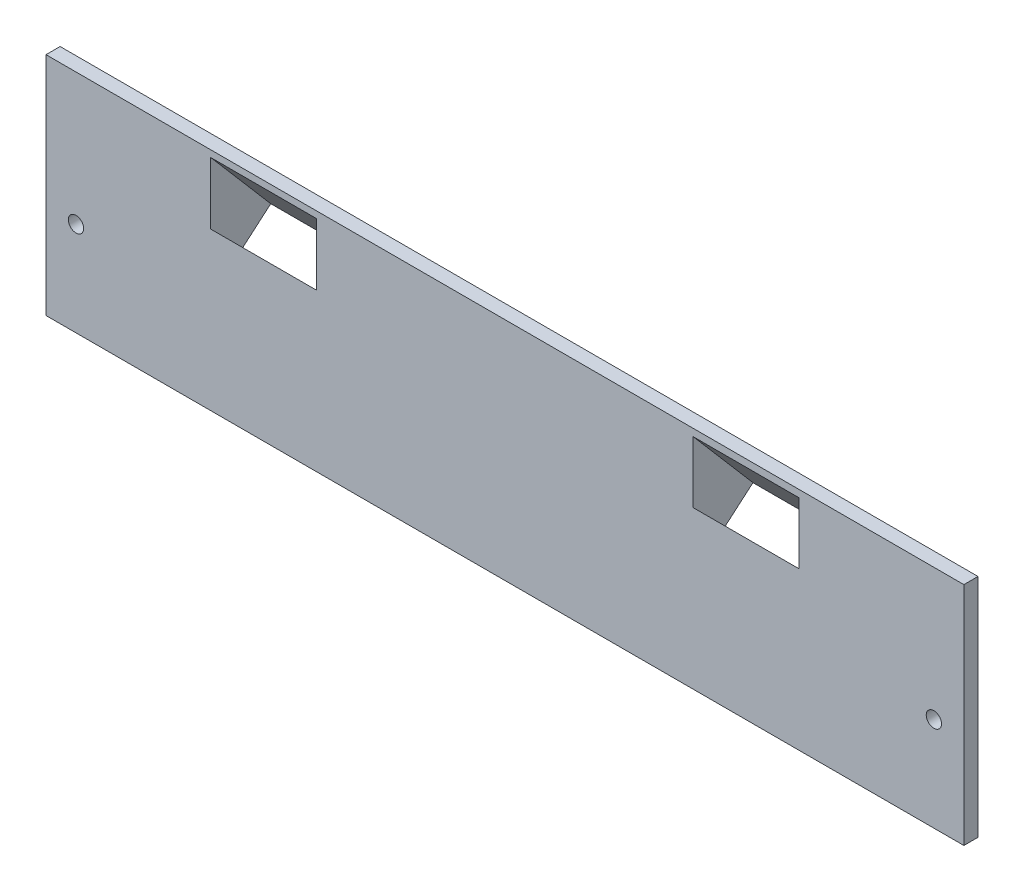
from build123d import *

# Parameters (mm, degrees)
CROQUIS1_W                 = 195
CROQUIS1_H                 = 38
CROQUIS1_R                 = 1.625
SALIENTE_EXTRUIR1_DEPTH    = 3
CROQUIS8_W                 = 195
CROQUIS8_H                 = 3
SALIENTE_EXTRUIR5_DEPTH    = 5
CROQUIS9_W                 = 195
CROQUIS9_H                 = 3
SALIENTE_EXTRUIR6_DEPTH    = 5
SALIENTE_EXTRUIR7_START    = -25
SALIENTE_EXTRUIR7_DEPTH    = 35
CROQUIS11_W                = 22.5
CROQUIS11_H                = 8.5
CORTAR_EXTRUIR4_DEPTH      = 24.953943013
CORTAR_EXTRUIR4_DEPTH_BACK = 22.667360251
CORTAR_EXTRUIR5_REACH      = 172
CROQUIS13_R                = 1
CORTAR_EXTRUIR6_DEPTH      = 5
SALIENTE_EXTRUIR8_START    = -25
SALIENTE_EXTRUIR8_DEPTH    = 35
CROQUIS16_W                = 22.5
CROQUIS16_H                = 8.572274099
CORTAR_EXTRUIR7_DEPTH      = 27.836407603
CORTAR_EXTRUIR7_DEPTH_BACK = 17.667360251
CROQUIS17_R                = 1
CORTAR_EXTRUIR8_DEPTH      = 5
CROQUIS18_W                = 35
CROQUIS18_H                = 12
CROQUIS18_R                = 1
CROQUIS18_W_2              = 22.5
CROQUIS18_H_2              = 8.572274099
CROQUIS18_H_3              = 8.5
SALIENTE_EXTRUIR9_DEPTH    = 4


with BuildPart() as part:
    # Croquis1 → Saliente-Extruir1 (new body)
    with BuildSketch(Plane.XY):
        with Locations((0, 19)):
            Rectangle(CROQUIS1_W, CROQUIS1_H)
        with Locations((91.125, 15)):
            Circle(CROQUIS1_R, mode=Mode.SUBTRACT)
        with Locations((-91.125, 15)):
            Circle(CROQUIS1_R, mode=Mode.SUBTRACT)
    extrude(amount=SALIENTE_EXTRUIR1_DEPTH)

    # Croquis8 → Saliente-Extruir5 (add)
    with BuildSketch(Plane.XZ):
        with Locations((0, 1.5)):
            Rectangle(CROQUIS8_W, CROQUIS8_H)
    extrude(amount=SALIENTE_EXTRUIR5_DEPTH)

    # Croquis9 → Saliente-Extruir6 (add)
    with BuildSketch(Plane(origin=(0, 38, 0), x_dir=(1, 0, 0), z_dir=(0, 1, 0))):
        with Locations((0, -1.5)):
            Rectangle(CROQUIS9_W, CROQUIS9_H)
    extrude(amount=SALIENTE_EXTRUIR6_DEPTH)

    # Croquis10 → Saliente-Extruir7 (add)
    with BuildSketch(Plane(origin=(97.5, 0, 0), x_dir=(0, 0, -1), z_dir=(1, 0, 0)).offset(SALIENTE_EXTRUIR7_START)):
        Polygon((0, 39.499839942), (11.100559408, 26.548595056), (1.230032412, 18.088530231), (0, 17.034264947), align=None)
    extrude(amount=-SALIENTE_EXTRUIR7_DEPTH)

    # Croquis11 → Cortar-Extruir4 (cut, two sides)
    with BuildSketch(Plane(origin=(0, 9.820133108, 8.416872039), x_dir=(1, 0, 0), z_dir=(0, -0.759271307, -0.650774217))) as cortar_extruir4_sk:
        with Locations((51.25, -20.45547742)):
            Rectangle(CROQUIS11_W, CROQUIS11_H)
    extrude(amount=CORTAR_EXTRUIR4_DEPTH, mode=Mode.SUBTRACT)
    extrude(cortar_extruir4_sk.sketch, amount=-CORTAR_EXTRUIR4_DEPTH_BACK, mode=Mode.SUBTRACT)

    # Croquis12 → Cortar-Extruir5 (cut, up to next)
    with BuildSketch(Plane(origin=(72.5, 0, 0), x_dir=(0, 0, -1), z_dir=(1, 0, 0)), mode=Mode.PRIVATE) as cortar_extruir5_sk1:
        Polygon((11.100559408, 26.548595056), (0, 17.034264947), (0, 23.619526305), (7.846688321, 30.344951592), align=None)
    cortar_extruir5_tool1 = extrude(cortar_extruir5_sk1.sketch, amount=-CORTAR_EXTRUIR5_REACH, mode=Mode.PRIVATE) & part.part
    add(cortar_extruir5_tool1.solids().sort_by_distance((72.5, 24.238262, -4.783378))[0], mode=Mode.SUBTRACT)

    # Croquis13 → Cortar-Extruir6 (cut)
    with BuildSketch(Plane(origin=(0, 13.616489645, 11.670743125), x_dir=(1, 0, 0), z_dir=(0, -0.759271307, -0.650774217))):
        with Locations((66.25, -20.20547742)):
            Circle(CROQUIS13_R)
    extrude(amount=-CORTAR_EXTRUIR6_DEPTH, mode=Mode.SUBTRACT)

    # Croquis14 → Saliente-Extruir8 (add)
    with BuildSketch(Plane.ZY.offset(97.5).offset(SALIENTE_EXTRUIR8_START)):
        Polygon((0, 23.619526305), (-7.846688321, 30.344951592), (0, 39.499839942), align=None)
    extrude(amount=-SALIENTE_EXTRUIR8_DEPTH)

    # Croquis16 → Cortar-Extruir7 (cut, two sides)
    with BuildSketch(Plane(origin=(0, 13.616489645, 11.670743125), x_dir=(1, 0, 0), z_dir=(0, -0.759271307, -0.650774217))) as cortar_extruir7_sk:
        with Locations((-51.25, -20.491614469)):
            Rectangle(CROQUIS16_W, CROQUIS16_H)
    extrude(amount=CORTAR_EXTRUIR7_DEPTH, mode=Mode.SUBTRACT)
    extrude(cortar_extruir7_sk.sketch, amount=-CORTAR_EXTRUIR7_DEPTH_BACK, mode=Mode.SUBTRACT)

    # Croquis17 → Cortar-Extruir8 (cut)
    with BuildSketch(Plane(origin=(0, 13.616489645, 11.670743125), x_dir=(1, 0, 0), z_dir=(0, -0.759271307, -0.650774217))):
        with Locations((-66.25, -20.20547742)):
            Circle(CROQUIS17_R)
    extrude(amount=-CORTAR_EXTRUIR8_DEPTH, mode=Mode.SUBTRACT)

    # Croquis18 → Saliente-Extruir9 (add)
    with BuildSketch(Plane(origin=(0, 13.616489645, 11.670743125), x_dir=(1, 0, 0), z_dir=(0, -0.759271307, -0.650774217))):
        with Locations((-55, -19.70547742)):
            Rectangle(CROQUIS18_W, CROQUIS18_H)
        with Locations((-66.25, -20.20547742)):
            Circle(CROQUIS18_R, mode=Mode.SUBTRACT)
        with Locations((-51.25, -20.491614469)):
            Rectangle(CROQUIS18_W_2, CROQUIS18_H_2, mode=Mode.SUBTRACT)
        with Locations((55, -19.70547742)):
            Rectangle(CROQUIS18_W, CROQUIS18_H)
        with Locations((66.25, -20.20547742)):
            Circle(CROQUIS18_R, mode=Mode.SUBTRACT)
        with Locations((51.25, -20.45547742)):
            Rectangle(CROQUIS18_W_2, CROQUIS18_H_3, mode=Mode.SUBTRACT)
    extrude(amount=SALIENTE_EXTRUIR9_DEPTH)


solid = part.part
